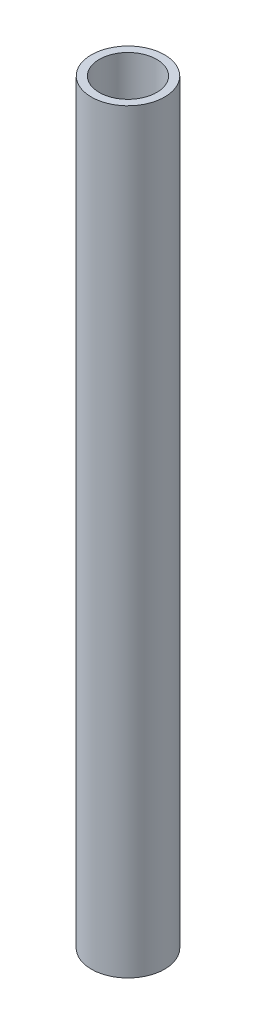
from build123d import *

# Parameters (mm, degrees)
SALIENTE_EXTRUIR1_DEPTH      = 165
SALIENTE_EXTRUIR1_DEPTH_BACK = 165
CROQUIS2_R                   = 16
CROQUIS4_R                   = 12.550824819
CORTAR_EXTRUIR1_DEPTH        = 210.5


with BuildPart() as part:
    # Croquis2 → Saliente-Extruir1 (new, two sides: drawn at the far end of the back side and taken through both)
    with BuildSketch(Plane(origin=(0, 0, 0), x_dir=(1, 0, 0), z_dir=(0, 1, 0)).offset(-SALIENTE_EXTRUIR1_DEPTH_BACK)):
        Circle(CROQUIS2_R)
    extrude(amount=SALIENTE_EXTRUIR1_DEPTH + SALIENTE_EXTRUIR1_DEPTH_BACK)

    # Croquis4 → Cortar-Extruir1 (cut, symmetric)
    with BuildSketch(Plane(origin=(0, 0, 0), x_dir=(1, 0, 0), z_dir=(0, 1, 0))):
        Circle(CROQUIS4_R)
    extrude(amount=CORTAR_EXTRUIR1_DEPTH, both=True, mode=Mode.SUBTRACT)


solid = part.part
